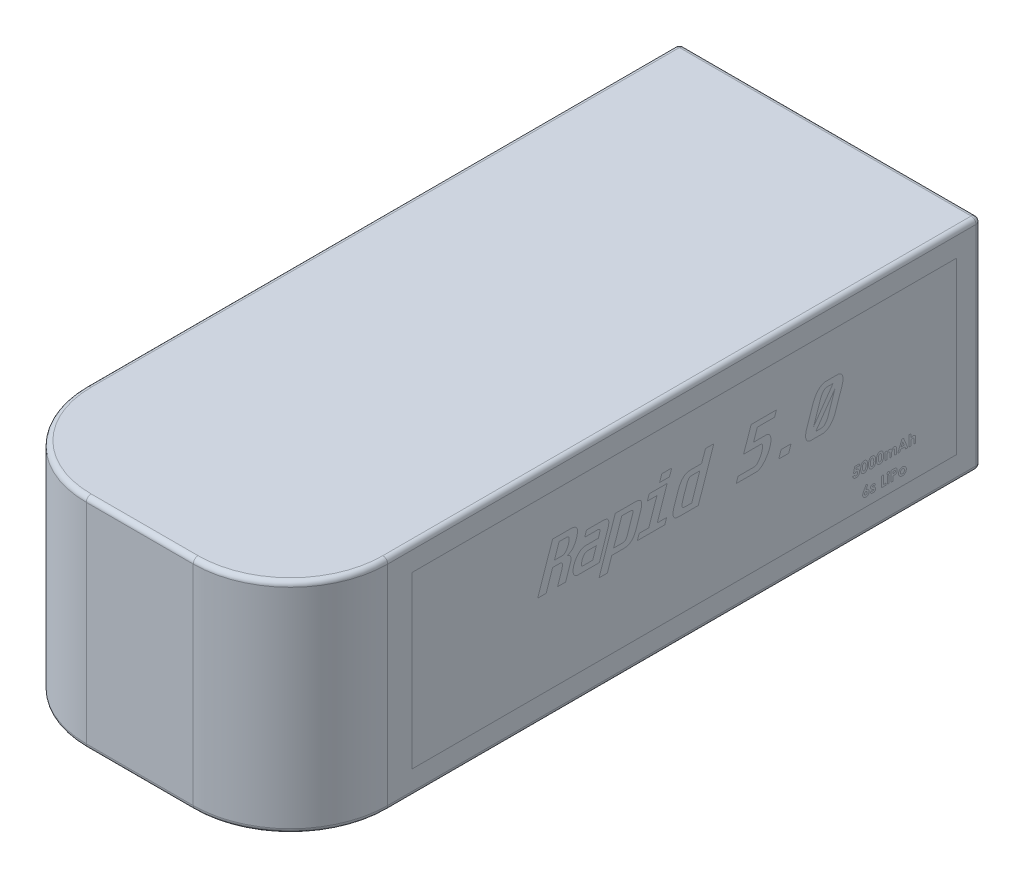
from build123d import *

# Parameters (mm, degrees)
SKETCH1_W           = 62
SKETCH1_H           = 45
BOSS_EXTRUDE1_DEPTH = 142
FILLET1_R           = 20
FILLET2_R           = 1


with BuildPart() as part:
    # Sketch1 → Boss-Extrude1 (new body)
    with BuildSketch(Plane.XY):
        Rectangle(SKETCH1_W, SKETCH1_H)
    extrude(amount=BOSS_EXTRUDE1_DEPTH)

    # Fillet1
    fillet1_edges = [part.edges().sort_by_distance(p)[0] for p in [
        (31, 0, 142),
        (-31, 0, 142),
    ]]
    fillet(fillet1_edges, radius=FILLET1_R)

    # Fillet2
    fillet2_edges = [part.edges().sort_by_distance(p)[0] for p in [
        (0, -22.5, 142),
        (0, 22.5, 142),
        (31, -22.5, 61),
        (-31, -22.5, 61),
        (25.142135624, -22.5, 136.142135624),
        (-25.142135624, -22.5, 136.142135624),
        (-31, 22.5, 61),
        (31, 22.5, 61),
        (25.142135624, 22.5, 136.142135624),
        (-25.142135624, 22.5, 136.142135624),
        (0, 22.5, 0),
        (31, 0, 0),
        (0, -22.5, 0),
        (-31, 0, 0),
    ]]
    fillet(fillet2_edges, radius=FILLET2_R)


solid = part.part
